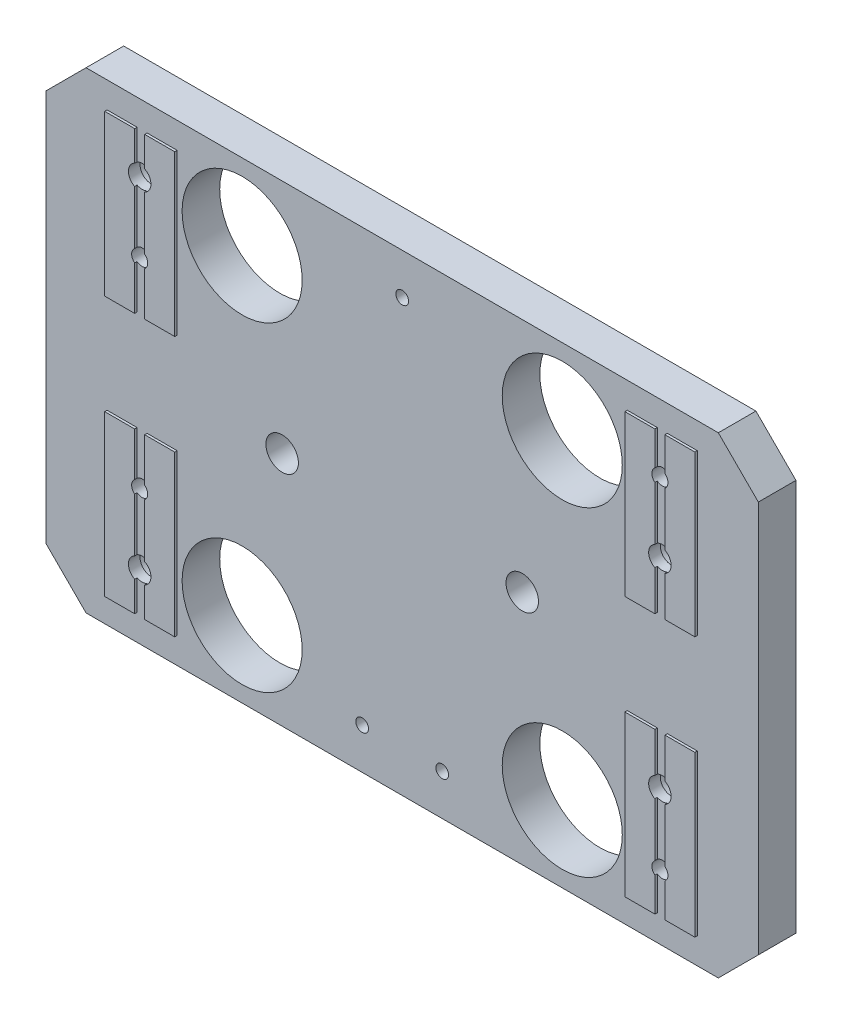
from build123d import *

# Parameters (mm, degrees)
SKETCH3_W                                     = 226.06
SKETCH3_H                                     = 149.86
EXTRUDE2_DEPTH                                = 12.7
SKETCH4_W                                     = 226.06
SKETCH4_H                                     = 149.86
SKETCH4_W_2                                   = 22.225
SKETCH4_H_2                                   = 50.8
EXTRUDE4_DEPTH                                = 0.762
CBORE_FOR_1_4_SOCKET_HEAD_CAP_SCREW1_AT_COUNT = 2
CBORE_FOR_1_4_SOCKET_HEAD_CAP_SCREW1_AT_PITCH = 186.028991356
CBORE_FOR_1_4_SOCKET_HEAD_CAP_SCREW1_2_COUNT  = 2
CBORE_FOR_1_4_SOCKET_HEAD_CAP_SCREW1_2_PITCH  = 166.589197204
CBORE_FOR_1_4_SOCKET_HEAD_CAP_SCREW1_3_COUNT  = 2
CBORE_FOR_1_4_SOCKET_HEAD_CAP_SCREW1_3_PITCH  = 63.5
F_1_1_DIAMETER_HOLE1_D                        = 38.1
F_10_32_TAPPED_HOLE1_D                        = 4.0386
SKETCH19_W                                    = 3.175
SKETCH19_H                                    = 133.35
CUT_EXTRUDE1_DEPTH                            = 0.762
F_1_4_20_TAPPED_HOLE1_D                       = 5.1054
CHAMFER1_SIZE                                 = 12.7
F_13_32_0_40625_DIAMETER_HOLE1_D              = 10.31875


with BuildPart() as part:
    # Sketch3 → Extrude2 (new body)
    with BuildSketch(Plane.XY):
        with Locations((113.03, -74.93)):
            Rectangle(SKETCH3_W, SKETCH3_H)
    extrude(amount=EXTRUDE2_DEPTH)

    # Sketch4 → Extrude4 (cut)
    with BuildSketch(Plane.XY.offset(12.7)):
        with Locations((113.03, -74.93)):
            Rectangle(SKETCH4_W, SKETCH4_H)
        with Locations((30.4927, -33.655)):
            Rectangle(SKETCH4_W_2, SKETCH4_H_2, mode=Mode.SUBTRACT)
        with Locations((30.4927, -116.205)):
            Rectangle(SKETCH4_W_2, SKETCH4_H_2, mode=Mode.SUBTRACT)
        with Locations((195.5673, -116.205)):
            Rectangle(SKETCH4_W_2, SKETCH4_H_2, mode=Mode.SUBTRACT)
        with Locations((195.5673, -33.655)):
            Rectangle(SKETCH4_W_2, SKETCH4_H_2, mode=Mode.SUBTRACT)
    extrude(amount=-EXTRUDE4_DEPTH, mode=Mode.SUBTRACT)

    # Sketch9 → CBORE for 1/4 Socket Head Cap Screw1 (revolve, cut)
    with BuildSketch(Plane(origin=(195.58, -106.68, 0), x_dir=(0, 1, 0), z_dir=(1, 0, 0))):
        Polygon((0, 0), (0, 12.7), (3.57124, 12.7), (3.57124, 9.017), (5.55625, 9.017), (5.55625, 0.635), (6.19125, 0), align=None)
    cbore_for_1_4_socket_head_cap_screw1 = revolve(axis=Axis((195.58, -106.68, -6.35), (0, 0, 1)), mode=Mode.SUBTRACT)

    # CBORE for 1/4 Socket Head Cap Screw1 at: CBORE for 1/4 Socket Head Cap Screw1 ×2
    with Locations(*[Vector(-0.887496077, 0.460815271, 0) * (i * CBORE_FOR_1_4_SOCKET_HEAD_CAP_SCREW1_AT_PITCH) for i in range(1, CBORE_FOR_1_4_SOCKET_HEAD_CAP_SCREW1_AT_COUNT)]):
        add(cbore_for_1_4_socket_head_cap_screw1, mode=Mode.SUBTRACT)

    # CBORE for 1_4 Socket Head Cap Screw1 2: CBORE for 1/4 Socket Head Cap Screw1 ×2
    with Locations(*[Vector(-0.991060662, -0.133412012, 0) * (i * CBORE_FOR_1_4_SOCKET_HEAD_CAP_SCREW1_2_PITCH) for i in range(1, CBORE_FOR_1_4_SOCKET_HEAD_CAP_SCREW1_2_COUNT)]):
        add(cbore_for_1_4_socket_head_cap_screw1, mode=Mode.SUBTRACT)

    # CBORE for 1_4 Socket Head Cap Screw1 3: CBORE for 1/4 Socket Head Cap Screw1 ×2
    with Locations(*[(0, i * CBORE_FOR_1_4_SOCKET_HEAD_CAP_SCREW1_3_PITCH, 0) for i in range(1, CBORE_FOR_1_4_SOCKET_HEAD_CAP_SCREW1_3_COUNT)]):
        add(cbore_for_1_4_socket_head_cap_screw1, mode=Mode.SUBTRACT)

    # 1 (1) Diameter Hole1 (through all)
    with Locations(Plane(origin=(163.83, -24.13, 0), x_dir=(-1, 0, 0), z_dir=(0, 0, -1))):
        with Locations((0, 0), (101.6, 0), (101.6, -101.6), (0, -101.6)):
            Hole(F_1_1_DIAMETER_HOLE1_D / 2)

    # #10-32 Tapped Hole1 (through all)
    with Locations(Plane(origin=(0, 0, 0), x_dir=(-1, 0, 0), z_dir=(0, 0, -1))):
        with Locations((-125.73, -136.8552), (-113.03, -13.0048), (-100.33, -136.8552)):
            Hole(F_10_32_TAPPED_HOLE1_D / 2)

    # Sketch19 → Cut-Extrude1 (cut)
    with BuildSketch(Plane.XY.offset(12.7)):
        with Locations((195.58, -74.93)):
            Rectangle(SKETCH19_W, SKETCH19_H)
        with Locations((30.48, -74.93)):
            Rectangle(SKETCH19_W, SKETCH19_H)
    extrude(amount=-CUT_EXTRUDE1_DEPTH, mode=Mode.SUBTRACT)

    # 1/4-20 Tapped Hole1 (through all)
    with Locations(Plane(origin=(0, 0, 0), x_dir=(-1, 0, 0), z_dir=(0, 0, -1))):
        with Locations((-195.58, -128.905), (-195.58, -20.955), (-30.48, -43.18), (-30.48, -106.68)):
            Hole(F_1_4_20_TAPPED_HOLE1_D / 2)

    # Chamfer1
    chamfer1_edges = [part.edges().sort_by_distance(p)[0] for p in [
        (0, 0, 5.969),
        (226.06, 0, 5.969),
        (226.06, -149.86, 5.969),
        (0, -149.86, 5.969),
    ]]
    chamfer(chamfer1_edges, length=CHAMFER1_SIZE)

    # 13/32 (0.40625) Diameter Hole1 (through all)
    with Locations(Plane(origin=(0, 0, 0), x_dir=(-1, 0, 0), z_dir=(0, 0, -1))):
        with Locations((-74.93, -74.93), (-151.13, -74.93)):
            Hole(F_13_32_0_40625_DIAMETER_HOLE1_D / 2)


solid = part.part
